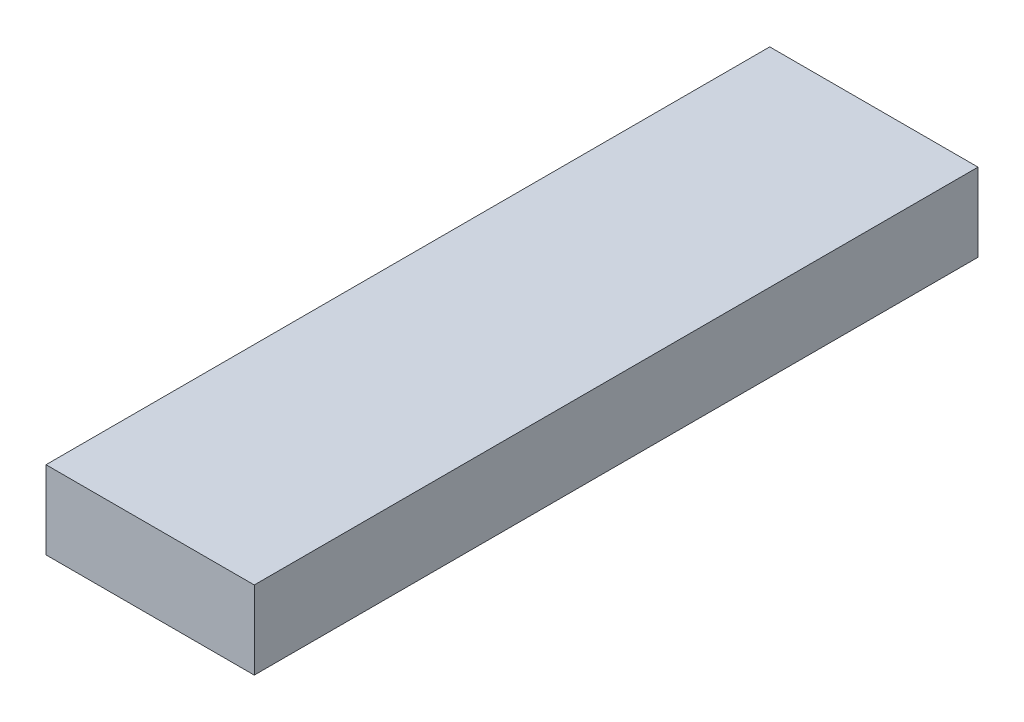
from build123d import *

# Parameters (mm, degrees)
SKETCH_1_W      = 80
SKETCH_1_H      = 278
EXTRUDE_1_DEPTH = 30


with BuildPart() as part:
    # Эскиз1 → Бобышка-Вытянуть1 (new body)
    with BuildSketch(Plane(origin=(0, 0, 0), x_dir=(1, 0, 0), z_dir=(0, 1, 0))):
        with Locations((40, 139)):
            Rectangle(SKETCH_1_W, SKETCH_1_H)
    extrude(amount=EXTRUDE_1_DEPTH)


solid = part.part
